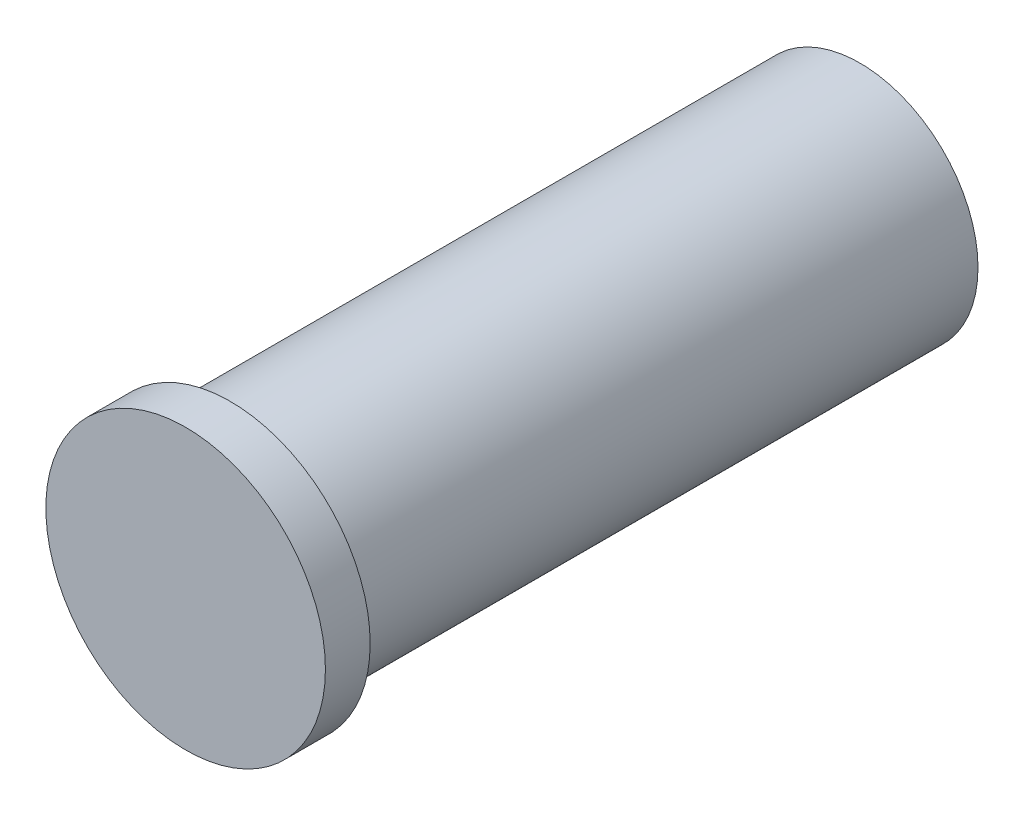
from build123d import *

# Parameters (mm, degrees)
SKETCH1_R           = 30
SKETCH1_R_2         = 27
BOSS_EXTRUDE1_DEPTH = 160
SCALE1_SCALE        = 0.703703704
SKETCH3_R           = 25
BOSS_EXTRUDE4_DEPTH = 8


with BuildPart() as part:
    # Sketch1 → Boss-Extrude1 (new body)
    with BuildSketch(Plane.XY):
        Circle(SKETCH1_R)
        Circle(SKETCH1_R_2, mode=Mode.SUBTRACT)
    extrude(amount=BOSS_EXTRUDE1_DEPTH)


with BuildPart() as part_1:
    # Scale1: scaled about (0, 0, 0)
    add(part.part.scale(SCALE1_SCALE))

    # Sketch3 → Boss-Extrude4 (add)
    with BuildSketch(Plane.XY.offset(112.592592607)):
        Circle(SKETCH3_R)
    extrude(amount=BOSS_EXTRUDE4_DEPTH)


solid = part_1.part
